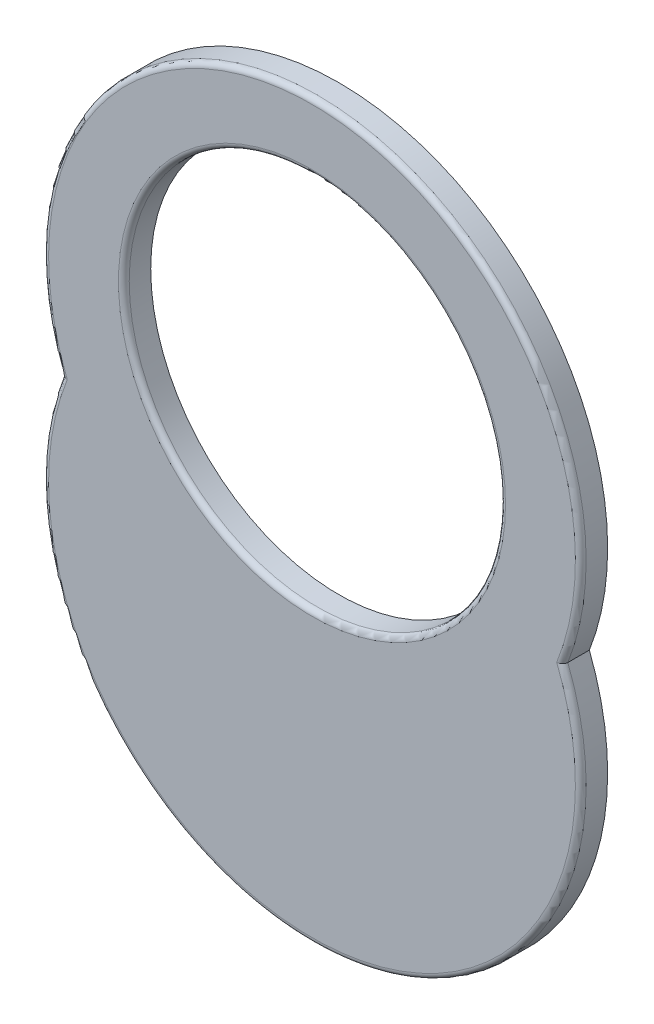
from build123d import *

# Parameters (mm, degrees)
SZKIC1_R                    = 14
DODANIE_WYCI_GNI_CIE1_DEPTH = 2
ZAOKR_GLENIE1_R             = 0.4


with BuildPart() as part:
    # Szkic1 → Dodanie-wyciągnięcie1 (new body)
    with BuildSketch(Plane.XY):
        with BuildLine():
            ThreePointArc((-18.639675426, 7.25), (0, -20), (18.639675426, 7.25))
            ThreePointArc((18.639675426, 7.25), (0, 34.5), (-18.639675426, 7.25))
        make_face()
        with Locations((0, 15.5)):
            Circle(SZKIC1_R, mode=Mode.SUBTRACT)
    extrude(amount=DODANIE_WYCI_GNI_CIE1_DEPTH)

    # Zaokrąglenie1
    zaokr_glenie1_edges = [part.edges().sort_by_distance(p)[0] for p in [
        (0, 34.5, 2),
        (-14, 15.5, 2),
        (0, -20, 2),
    ]]
    fillet(zaokr_glenie1_edges, radius=ZAOKR_GLENIE1_R)


solid = part.part
